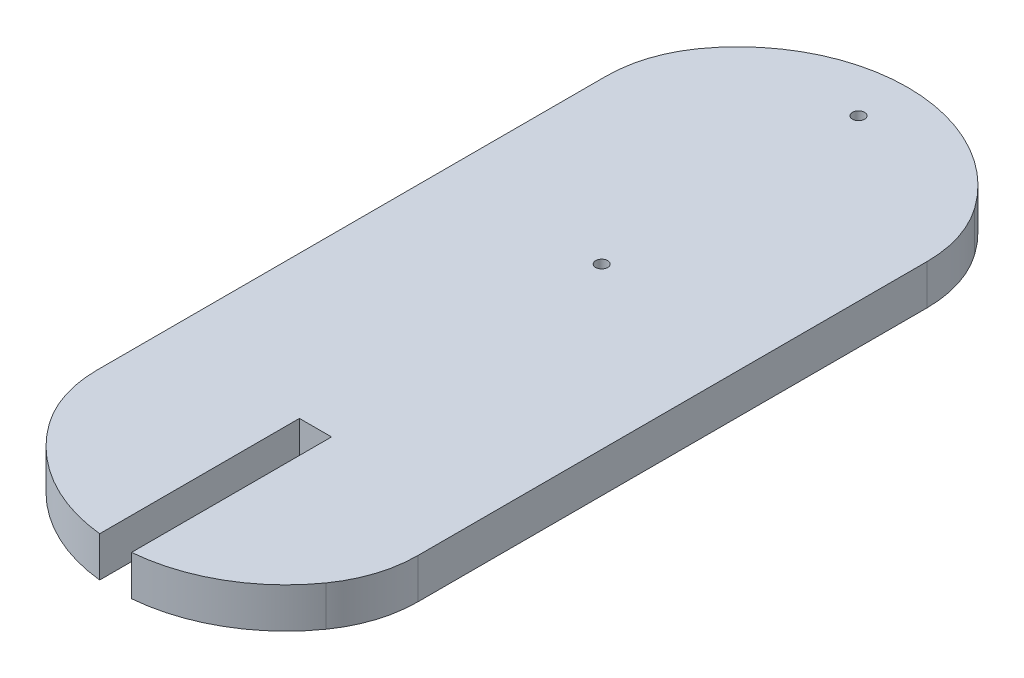
from build123d import *

# Parameters (mm, degrees)
SKETCH2_W           = 40
SKETCH2_H           = 70
BOSS_EXTRUDE1_DEPTH = 5
FILLET1_R           = 15
CUT_EXTRUDE1_DEPTH  = 6
SKETCH4_R           = 0.75
CUT_EXTRUDE2_DEPTH  = 6


with BuildPart() as part:
    # Sketch2 → Boss-Extrude1 (new body)
    with BuildSketch(Plane(origin=(0, 0, 0), x_dir=(1, 0, 0), z_dir=(0, 1, 0))):
        with BuildLine():
            Line((-20, -35), (20, -35))
            ThreePointArc((20, -35), (0, -49.312603136), (-20, -35))
        make_face()
        Rectangle(SKETCH2_W, SKETCH2_H)
        with BuildLine():
            ThreePointArc((-20, 35), (0, 49.305454963), (20, 35))
            Line((20, 35), (-20, 35))
        make_face()
    extrude(amount=BOSS_EXTRUDE1_DEPTH)

    # Fillet1
    fillet1_edges = [part.edges().sort_by_distance(p)[0] for p in [
        (-20, 2.5, 35),
        (-20, 2.5, -35),
        (20, 2.5, -35),
        (20, 2.5, 35),
    ]]
    fillet(fillet1_edges, radius=FILLET1_R)

    # Sketch3 → Cut-Extrude1 (cut, through all)
    with BuildSketch(Plane.XZ):
        Polygon((0, 49.312603136), (1.823748233, 49.312603136), (1.823748233, 24.312603136), (-2.176251767, 24.312603136), (-2.176251767, 49.312603136), align=None)
    extrude(amount=-CUT_EXTRUDE1_DEPTH, mode=Mode.SUBTRACT)

    # Sketch4 → Cut-Extrude2 (cut, through all)
    with BuildSketch(Plane.XZ):
        with Locations((0, -43.172046648)):
            Circle(SKETCH4_R)
        with Locations((0, -11.172046648)):
            Circle(SKETCH4_R)
    extrude(amount=-CUT_EXTRUDE2_DEPTH, mode=Mode.SUBTRACT)


solid = part.part
